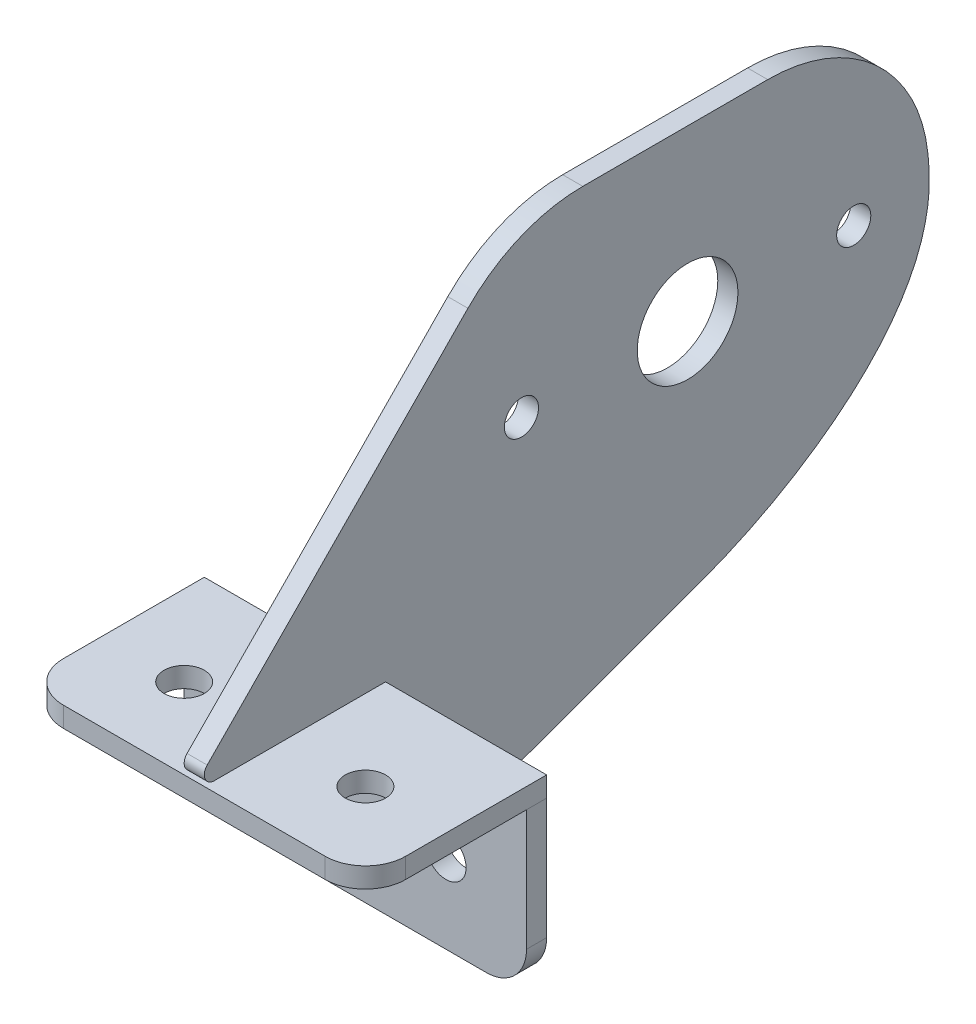
from build123d import *

# Parameters (mm, degrees)
SKETCH1_R           = 7.9375
BOSS_EXTRUDE1_DEPTH = 3.175
SKETCH2_R           = 3.175
BOSS_EXTRUDE2_DEPTH = 3.175
SKETCH3_R           = 3.175
BOSS_EXTRUDE3_DEPTH = 3.175
SKETCH4_R           = 2.6924
CUT_EXTRUDE1_DEPTH  = 29.575
FILLET1_R           = 25.4


with BuildPart() as part:
    # Sketch1 → Boss-Extrude1 (new body)
    with BuildSketch(Plane(origin=(0, 0, 0), x_dir=(0, 0, -1), z_dir=(1, 0, 0))):
        with BuildLine():
            Line((-27.169618094, 26.70995793), (-75.743368037, -22.69971313))
            ThreePointArc((-75.743368037, -22.69971313), (-76.075354693, -24.426388512), (-74.611300617, -25.400128043))
            Line((-74.611300617, -25.400128043), (-47.623800617, -25.400128043))
            Line((-47.623800617, -25.400128043), (-47.623800617, -52.387628043))
            ThreePointArc((-47.623800617, -52.387628043), (-46.946853209, -53.688031914), (-45.493343639, -53.879390079))
            Line((-45.493343639, -53.879390079), (2.243041497, -36.504766798))
            add(Edge.make_bspline(
                [(38.098613574, 0.325028819), (38.257943408, -18.350994418), (16.130398484, -31.450182222), (2.243041497, -36.504766798)],
                knots=[0, 0, 0, 0, 1, 1, 1, 1], degree=3))
            ThreePointArc((38.098613574, 0.325028819), (14.279420738, 35.322912442), (-27.169618094, 26.70995793))
        make_face()
        Circle(SKETCH1_R, mode=Mode.SUBTRACT)
    extrude(amount=BOSS_EXTRUDE1_DEPTH)

    # Sketch4 → Cut-Extrude1 (cut, through all)
    with BuildSketch(Plane(origin=(3.175, 0, 0), x_dir=(0, 0, -1), z_dir=(1, 0, 0))):
        with Locations((-26.19375, 0)):
            Circle(SKETCH4_R)
        with Locations((26.19375, 0)):
            Circle(SKETCH4_R)
        with BuildLine():
            Line((27.169618094, 26.70995793), (-27.169618094, 26.70995793))
            ThreePointArc((-27.169618094, 26.70995793), (0, 38.1), (27.169618094, 26.70995793))
        make_face()
    extrude(amount=-CUT_EXTRUDE1_DEPTH, mode=Mode.SUBTRACT)

    # Fillet1
    fillet1_edges = [part.edges().sort_by_distance(p)[0] for p in [
        (1.5875, 26.70995793, 27.169618094),
        (1.5875, 26.70995793, -27.169618094),
    ]]
    fillet(fillet1_edges, radius=FILLET1_R)


with BuildPart() as body_2:
    # Sketch2 → Boss-Extrude2 (new body)
    with BuildSketch(Plane(origin=(38.098793801, -25.400128043, 0), x_dir=(0, 0, -1), z_dir=(0, -1, 0))):
        with BuildLine():
            Line((-69.848800617, -9.523793801), (-47.623800617, -9.523793801))
            Line((-47.623800617, -9.523793801), (-47.623800617, -63.498793801))
            Line((-47.623800617, -63.498793801), (-69.848800617, -63.498793801))
            ThreePointArc((-69.848800617, -63.498793801), (-74.338928677, -61.638921862), (-76.198800617, -57.148793801))
            Line((-76.198800617, -57.148793801), (-76.198800617, -15.873793801))
            ThreePointArc((-76.198800617, -15.873793801), (-74.338928677, -11.383665741), (-69.848800617, -9.523793801))
        make_face()
        with Locations((-63.498800617, -22.223793801)):
            Circle(SKETCH2_R, mode=Mode.SUBTRACT)
        with Locations((-63.498800617, -50.798793801)):
            Circle(SKETCH2_R, mode=Mode.SUBTRACT)
    extrude(amount=BOSS_EXTRUDE2_DEPTH)


with BuildPart() as body_3:
    # Sketch3 → Boss-Extrude3 (new body)
    with BuildSketch(Plane.XY.offset(47.623800617)):
        with BuildLine():
            Line((-25.4, -28.575128043), (28.575, -28.575128043))
            Line((28.575, -28.575128043), (28.575, -47.625128043))
            ThreePointArc((28.575, -47.625128043), (26.715128061, -52.115256104), (22.225, -53.975128043))
            Line((22.225, -53.975128043), (-19.05, -53.975128043))
            ThreePointArc((-19.05, -53.975128043), (-23.540128061, -52.115256104), (-25.4, -47.625128043))
            Line((-25.4, -47.625128043), (-25.4, -28.575128043))
        make_face()
        with Locations((-12.7, -41.275128043)):
            Circle(SKETCH3_R, mode=Mode.SUBTRACT)
        with Locations((15.875, -41.275128043)):
            Circle(SKETCH3_R, mode=Mode.SUBTRACT)
    extrude(amount=BOSS_EXTRUDE3_DEPTH)


solid = Compound([part.part, body_2.part, body_3.part])
